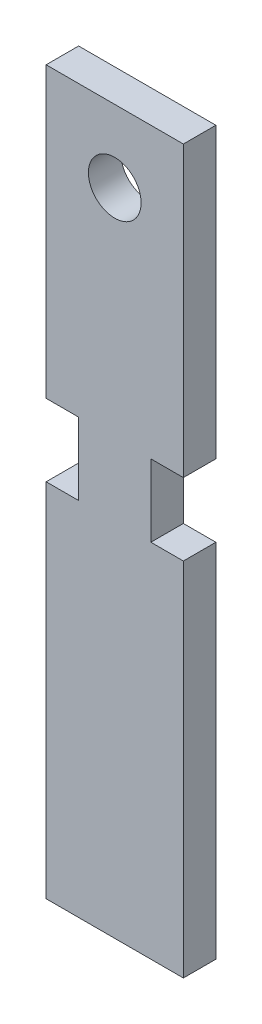
from build123d import *

# Parameters (mm, degrees)
SKETCH1_W           = 50.8
SKETCH1_H           = 127
BOSS_EXTRUDE1_DEPTH = 5.715
SKETCH2_R           = 4.6355
SKETCH2_W           = 5.715
SKETCH2_H           = 12.7
CUT_EXTRUDE1_DEPTH  = 6.715
CUT_EXTRUDE2_DEPTH  = 6.715


with BuildPart() as part:
    # Sketch1 → Boss-Extrude1 (new body)
    with BuildSketch(Plane.XY):
        Rectangle(SKETCH1_W, SKETCH1_H)
    extrude(amount=BOSS_EXTRUDE1_DEPTH)

    # Sketch2 → Cut-Extrude1 (cut, through all)
    with BuildSketch(Plane.XY.offset(5.715)):
        with Locations((0, 50.8)):
            Circle(SKETCH2_R)
        with Locations((-9.2075, 6.35)):
            Rectangle(SKETCH2_W, SKETCH2_H)
        with Locations((9.2075, 6.35)):
            Rectangle(SKETCH2_W, SKETCH2_H)
    extrude(amount=-CUT_EXTRUDE1_DEPTH, mode=Mode.SUBTRACT)

    # Sketch3 → Cut-Extrude2 (cut, through all)
    with BuildSketch(Plane.XY.offset(5.715)):
        Polygon((-12.065, 12.7), (-12.065, 63.5), (-25.4, 63.5), (-25.4, -63.5), (-12.065, -63.5), (-12.065, 0), align=None)
        Polygon((25.4, 63.5), (12.065, 63.5), (12.065, 12.7), (12.065, 0), (12.065, -63.5), (25.4, -63.5), align=None)
    extrude(amount=-CUT_EXTRUDE2_DEPTH, mode=Mode.SUBTRACT)


solid = part.part
